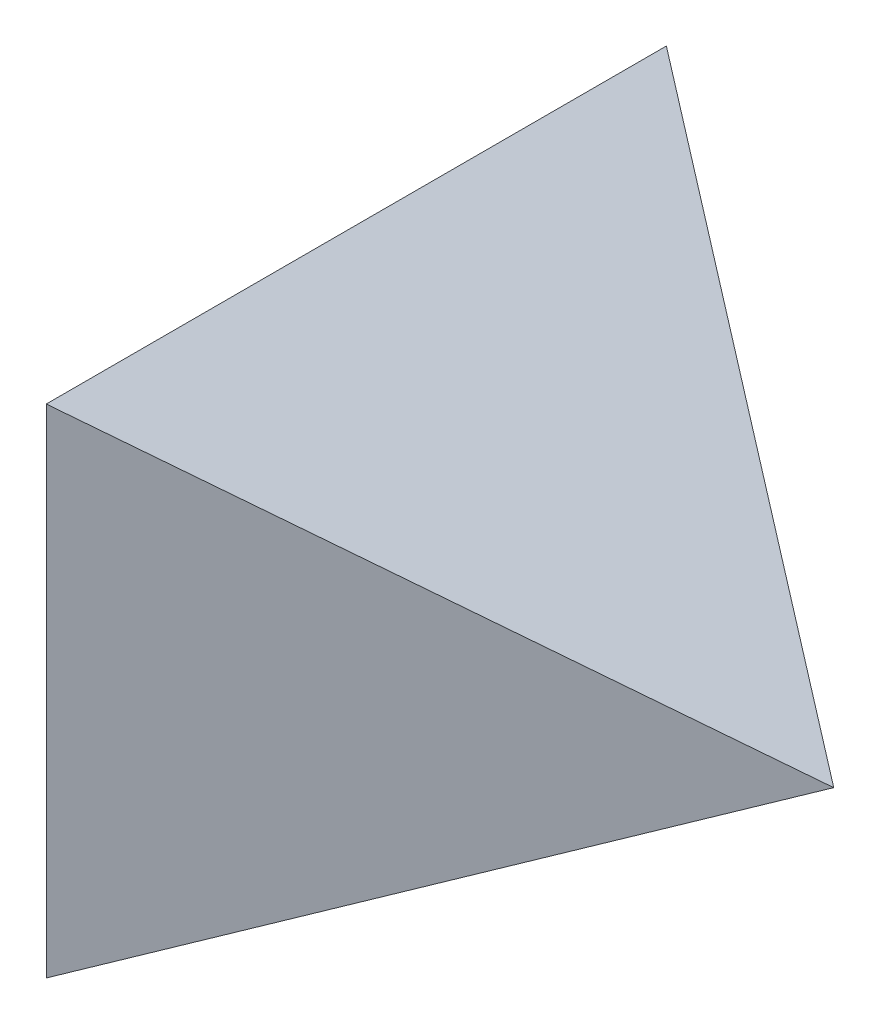
from build123d import *

# Parameters (mm, degrees)
BOSS_EXTRUDE1_DEPTH      = 3000
BOSS_EXTRUDE1_DEPTH_BACK = 3000
CUT_EXTRUDE1_DEPTH       = 3000
CUT_EXTRUDE1_DEPTH_BACK  = 3000
SKETCH2_OUTSIDE_W        = 4481.942
SKETCH2_OUTSIDE_H        = 7481.942


with BuildPart() as part:
    # Sketch1 → Boss-Extrude1 (new, two sides: drawn at the far end of the back side and taken through both)
    with BuildSketch(Plane.XY.offset(-BOSS_EXTRUDE1_DEPTH_BACK)):
        Polygon((0, 0), (-3000, 1561.701151655), (-3000, -1561.701151655), align=None)
    extrude(amount=BOSS_EXTRUDE1_DEPTH + BOSS_EXTRUDE1_DEPTH_BACK)

    # Sketch2 outside → Cut-Extrude1 (cut, two sides: drawn at the far end of the back side and taken through both)
    with BuildSketch(Plane(origin=(0, 0, 0), x_dir=(1, 0, 0), z_dir=(0, 1, 0)).offset(-CUT_EXTRUDE1_DEPTH_BACK)):
        with Locations((-1500, 0)):
            Rectangle(SKETCH2_OUTSIDE_W, SKETCH2_OUTSIDE_H)
        Polygon((0, 0), (-3000, 1948.222779593), (-3000, -1948.222779593), align=None, mode=Mode.SUBTRACT)
    extrude(amount=CUT_EXTRUDE1_DEPTH + CUT_EXTRUDE1_DEPTH_BACK, mode=Mode.SUBTRACT)


solid = part.part
